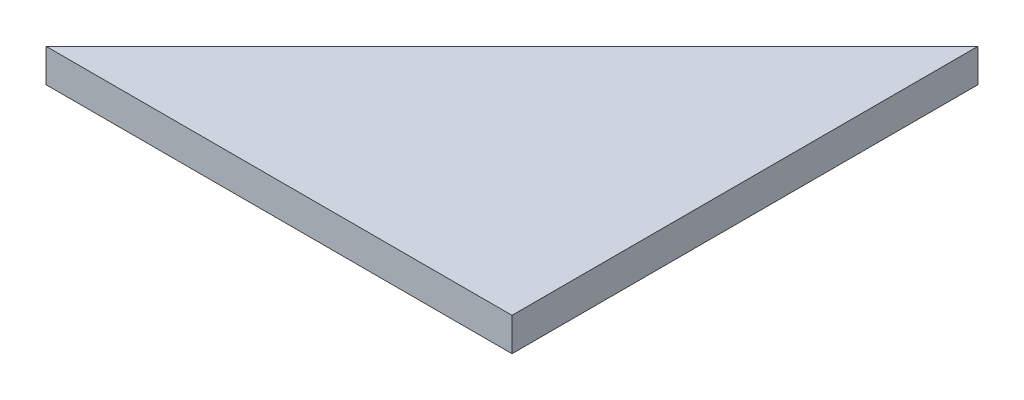
from build123d import *

# Parameters (mm, degrees)
BOSS_EXTRUDE1_DEPTH = 3


with BuildPart() as part:
    # Sketch1 → Boss-Extrude1 (new body)
    with BuildSketch(Plane(origin=(0, 0, 0), x_dir=(1, 0, 0), z_dir=(0, 1, 0))):
        Polygon((-21, -11.714876033), (21, 30.285123967), (21, -11.714876033), align=None)
    extrude(amount=BOSS_EXTRUDE1_DEPTH)


solid = part.part
